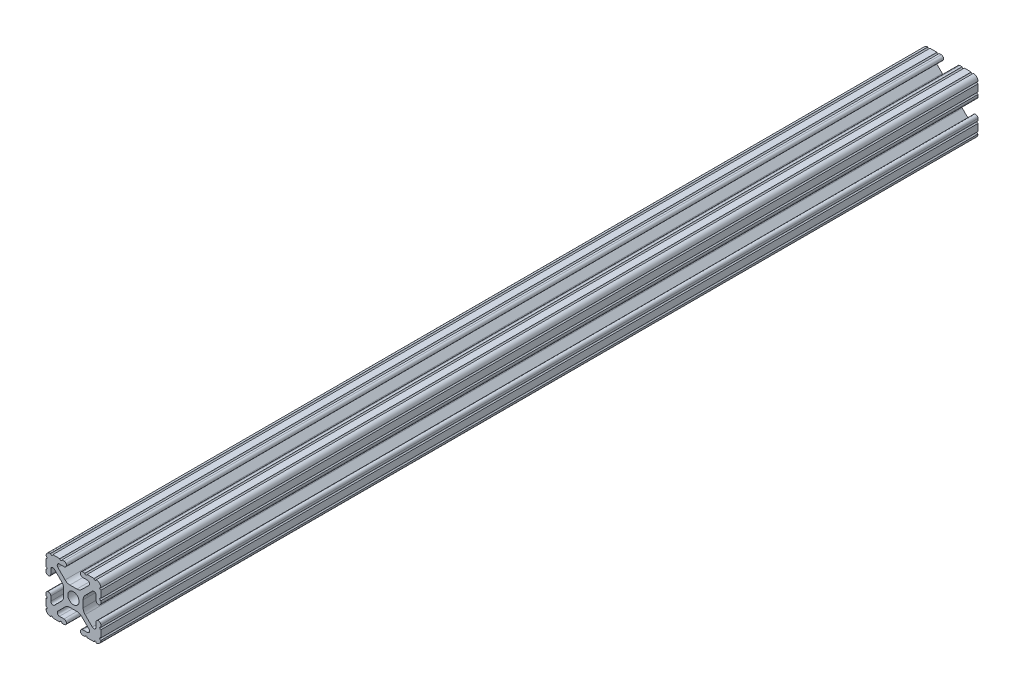
from build123d import *

# Parameters (mm, degrees)
SKETCH1_R           = 2.6035
BOSS_EXTRUDE1_DEPTH = 406.4


with BuildPart() as part:
    # Sketch1 → Boss-Extrude1 (new body)
    with BuildSketch(Plane(origin=(0, 0, -450.85), x_dir=(-1, 0, 0), z_dir=(0, 0, -1))):
        with BuildLine():
            Line((12.7, -9.5504), (12.7, -6.3330836))
            ThreePointArc((12.7, -6.3330836), (12.192, -5.8250836), (12.7, -5.3170836))
            Line((12.7, -5.3170836), (12.7, -4.3434))
            ThreePointArc((12.7, -4.3434), (11.5951, -3.2385), (10.4902, -4.3434))
            Line((10.4902, -4.3434), (10.4902, -6.474794456))
            ThreePointArc((10.4902, -6.474794456), (9.863006367, -7.413456061), (8.75577951, -7.193214945))
            Line((8.75577951, -7.193214945), (5.42573597, -3.863171405))
            ThreePointArc((5.42573597, -3.863171405), (4.737482484, -2.833127272), (4.4958, -1.618107374))
            Line((4.4958, -1.618107374), (4.4958, 1.618107374))
            ThreePointArc((4.4958, 1.618107374), (4.737482484, 2.833127272), (5.42573597, 3.863171405))
            Line((5.42573597, 3.863171405), (8.75577951, 7.193214945))
            ThreePointArc((8.75577951, 7.193214945), (9.863006367, 7.413456061), (10.4902, 6.474794456))
            Line((10.4902, 6.474794456), (10.4902, 4.343399971))
            ThreePointArc((10.4902, 4.343399971), (11.5951, 3.238499971), (12.7, 4.343399971))
            Line((12.7, 4.343399971), (12.7, 5.3170836))
            ThreePointArc((12.7, 5.3170836), (12.192, 5.8250836), (12.7, 6.3330836))
            Line((12.7, 6.3330836), (12.7, 9.5504))
            ThreePointArc((12.7, 9.5504), (12.192000006, 10.058323491), (12.699846982, 10.566399977))
            ThreePointArc((12.699846982, 10.566399977), (12.082522516, 12.082522516), (10.566399977, 12.699846982))
            ThreePointArc((10.566399977, 12.699846982), (10.058323491, 12.192000006), (9.5504, 12.7))
            Line((9.5504, 12.7), (6.3330836, 12.7))
            ThreePointArc((6.3330836, 12.7), (5.8250836, 12.192), (5.3170836, 12.7))
            Line((5.3170836, 12.7), (4.3434, 12.7))
            ThreePointArc((4.3434, 12.7), (3.2385, 11.5951), (4.3434, 10.4902))
            Line((4.3434, 10.4902), (6.474794456, 10.4902))
            ThreePointArc((6.474794456, 10.4902), (7.413456061, 9.863006367), (7.193214945, 8.75577951))
            Line((7.193214945, 8.75577951), (3.863171405, 5.42573597))
            ThreePointArc((3.863171405, 5.42573597), (2.833127272, 4.737482484), (1.618107374, 4.4958))
            Line((1.618107374, 4.4958), (-1.618107374, 4.4958))
            ThreePointArc((-1.618107374, 4.4958), (-2.833127272, 4.737482484), (-3.863171405, 5.42573597))
            Line((-3.863171405, 5.42573597), (-7.193214945, 8.75577951))
            ThreePointArc((-7.193214945, 8.75577951), (-7.413456061, 9.863006367), (-6.474794456, 10.4902))
            Line((-6.474794456, 10.4902), (-4.343399971, 10.4902))
            ThreePointArc((-4.343399971, 10.4902), (-3.238499971, 11.5951), (-4.343399971, 12.7))
            Line((-4.343399971, 12.7), (-5.3170836, 12.7))
            ThreePointArc((-5.3170836, 12.7), (-5.8250836, 12.192), (-6.3330836, 12.7))
            Line((-6.3330836, 12.7), (-9.5504, 12.7))
            ThreePointArc((-9.5504, 12.7), (-10.058323491, 12.192000006), (-10.566399977, 12.699846982))
            ThreePointArc((-10.566399977, 12.699846982), (-12.082522516, 12.082522516), (-12.699846982, 10.566399977))
            ThreePointArc((-12.699846982, 10.566399977), (-12.192000006, 10.058323491), (-12.7, 9.5504))
            Line((-12.7, 9.5504), (-12.7, 6.3330836))
            ThreePointArc((-12.7, 6.3330836), (-12.192, 5.8250836), (-12.7, 5.3170836))
            Line((-12.7, 5.3170836), (-12.7, 4.3434))
            ThreePointArc((-12.7, 4.3434), (-11.5951, 3.2385), (-10.4902, 4.3434))
            Line((-10.4902, 4.3434), (-10.4902, 6.474794456))
            ThreePointArc((-10.4902, 6.474794456), (-9.863006367, 7.413456061), (-8.75577951, 7.193214945))
            Line((-8.75577951, 7.193214945), (-5.42573597, 3.863171405))
            ThreePointArc((-5.42573597, 3.863171405), (-4.737482484, 2.833127272), (-4.4958, 1.618107374))
            Line((-4.4958, 1.618107374), (-4.4958, -1.618107374))
            ThreePointArc((-4.4958, -1.618107374), (-4.737482484, -2.833127272), (-5.42573597, -3.863171405))
            Line((-5.42573597, -3.863171405), (-8.75577951, -7.193214945))
            ThreePointArc((-8.75577951, -7.193214945), (-9.863006367, -7.413456061), (-10.4902, -6.474794456))
            Line((-10.4902, -6.474794456), (-10.4902, -4.343399971))
            ThreePointArc((-10.4902, -4.343399971), (-11.5951, -3.238499971), (-12.7, -4.343399971))
            Line((-12.7, -4.343399971), (-12.7, -5.3170836))
            ThreePointArc((-12.7, -5.3170836), (-12.192, -5.8250836), (-12.7, -6.3330836))
            Line((-12.7, -6.3330836), (-12.7, -9.5504))
            ThreePointArc((-12.7, -9.5504), (-12.192000006, -10.058323491), (-12.699846982, -10.566399977))
            ThreePointArc((-12.699846982, -10.566399977), (-12.082522516, -12.082522516), (-10.566399977, -12.699846982))
            ThreePointArc((-10.566399977, -12.699846982), (-10.058323491, -12.192000006), (-9.5504, -12.7))
            Line((-9.5504, -12.7), (-6.3330836, -12.7))
            ThreePointArc((-6.3330836, -12.7), (-5.8250836, -12.192), (-5.3170836, -12.7))
            Line((-5.3170836, -12.7), (-4.3434, -12.7))
            ThreePointArc((-4.3434, -12.7), (-3.2385, -11.5951), (-4.3434, -10.4902))
            Line((-4.3434, -10.4902), (-6.474794456, -10.4902))
            ThreePointArc((-6.474794456, -10.4902), (-7.413456061, -9.863006367), (-7.193214945, -8.75577951))
            Line((-7.193214945, -8.75577951), (-3.863171405, -5.42573597))
            ThreePointArc((-3.863171405, -5.42573597), (-2.833127272, -4.737482484), (-1.618107374, -4.4958))
            Line((-1.618107374, -4.4958), (1.618107374, -4.4958))
            ThreePointArc((1.618107374, -4.4958), (2.833127272, -4.737482484), (3.863171405, -5.42573597))
            Line((3.863171405, -5.42573597), (7.193214945, -8.75577951))
            ThreePointArc((7.193214945, -8.75577951), (7.413456061, -9.863006367), (6.474794456, -10.4902))
            Line((6.474794456, -10.4902), (4.343399971, -10.4902))
            ThreePointArc((4.343399971, -10.4902), (3.238499971, -11.5951), (4.343399971, -12.7))
            Line((4.343399971, -12.7), (5.3170836, -12.7))
            ThreePointArc((5.3170836, -12.7), (5.8250836, -12.192), (6.3330836, -12.7))
            Line((6.3330836, -12.7), (9.5504, -12.7))
            ThreePointArc((9.5504, -12.7), (10.058323491, -12.192000006), (10.566399977, -12.699846982))
            ThreePointArc((10.566399977, -12.699846982), (12.082522516, -12.082522516), (12.699846982, -10.566399977))
            ThreePointArc((12.699846982, -10.566399977), (12.192000006, -10.058323491), (12.7, -9.5504))
        make_face()
        Circle(SKETCH1_R, mode=Mode.SUBTRACT)
    extrude(amount=-BOSS_EXTRUDE1_DEPTH)


solid = part.part
